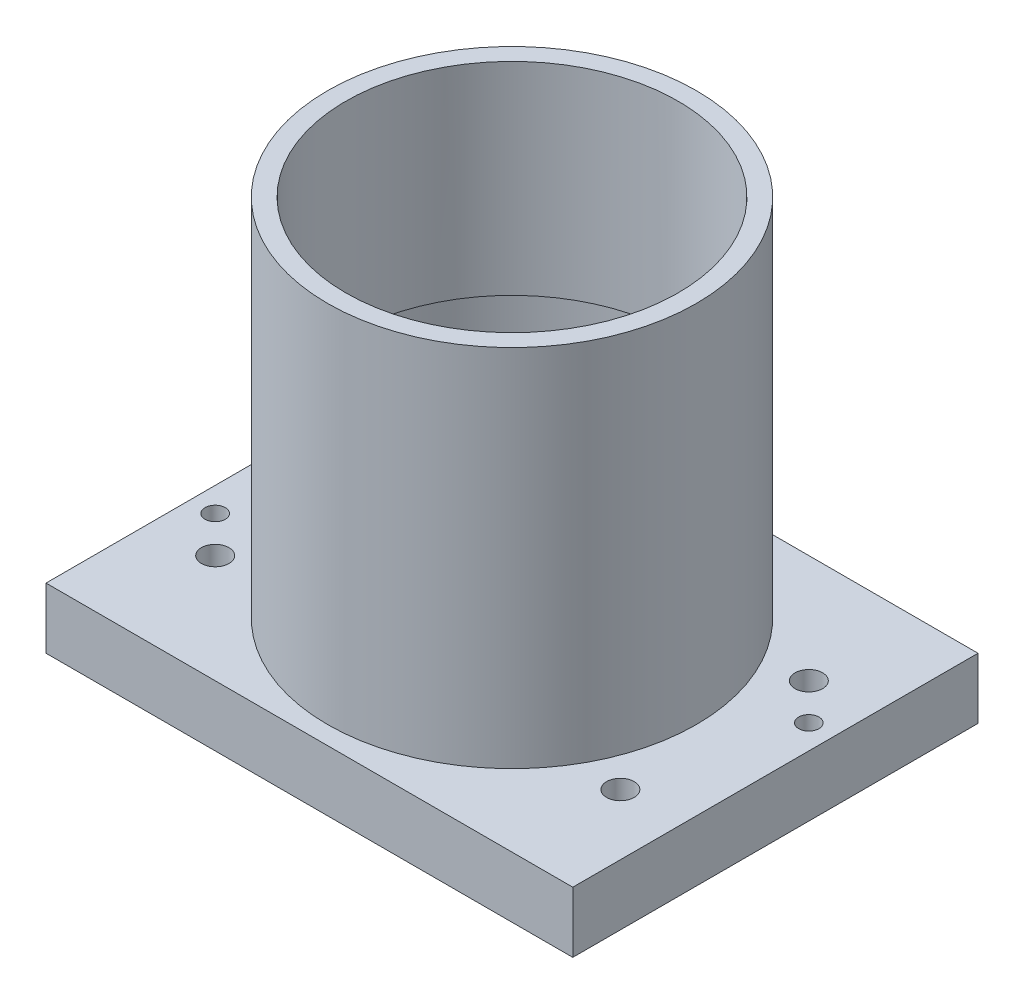
from build123d import *

# Parameters (mm, degrees)
SKETCH1_W             = 130
SKETCH1_H             = 100
BOSS_EXTRUDE1_DEPTH   = 15
SKETCH2_R             = 45.5
BOSS_EXTRUDE2_DEPTH   = 90
SKETCH3_R             = 41
CUT_EXTRUDE1_DEPTH    = 106
SKETCH4_R             = 42.5
CUT_EXTRUDE2_DEPTH    = 55
M8_TAPPED_HOLE1_D     = 6.8
M8_TAPPED_HOLE1_DEPTH = 17.707073895
M8_TAPPED_HOLE1_TIP   = 2.042926105
SKETCH11_R            = 2.5
CUT_EXTRUDE3_DEPTH    = 106


with BuildPart() as part:
    # Sketch1 → Boss-Extrude1 (new body)
    with BuildSketch(Plane(origin=(0, 0, 0), x_dir=(1, 0, 0), z_dir=(0, 1, 0))):
        Rectangle(SKETCH1_W, SKETCH1_H)
    extrude(amount=BOSS_EXTRUDE1_DEPTH)

    # Sketch2 → Boss-Extrude2 (add)
    with BuildSketch(Plane(origin=(0, 15, 0), x_dir=(1, 0, 0), z_dir=(0, 1, 0))):
        Circle(SKETCH2_R)
    extrude(amount=BOSS_EXTRUDE2_DEPTH)

    # Sketch3 → Cut-Extrude1 (cut, through all)
    with BuildSketch(Plane(origin=(0, 105, 0), x_dir=(1, 0, 0), z_dir=(0, 1, 0))):
        Circle(SKETCH3_R)
    extrude(amount=-CUT_EXTRUDE1_DEPTH, mode=Mode.SUBTRACT)

    # Sketch4 → Cut-Extrude2 (cut)
    with BuildSketch(Plane.XZ):
        Circle(SKETCH4_R)
    extrude(amount=-CUT_EXTRUDE2_DEPTH, mode=Mode.SUBTRACT)

    # M8 Tapped Hole1
    with Locations(Plane(origin=(0, 15, 0), x_dir=(1, 0, 0), z_dir=(0, 1, 0))):
        with Locations((-50, 23.25), (-50, -23.25), (50, -23.25), (50, 23.25)):
            Hole(M8_TAPPED_HOLE1_D / 2, depth=M8_TAPPED_HOLE1_DEPTH)
            with Locations((0, 0, -(M8_TAPPED_HOLE1_DEPTH + M8_TAPPED_HOLE1_TIP / 2))):  # 118° drill point
                Cone(0, M8_TAPPED_HOLE1_D / 2, M8_TAPPED_HOLE1_TIP, mode=Mode.SUBTRACT)

    # Sketch11 → Cut-Extrude3 (cut, through all)
    with BuildSketch(Plane.XZ):
        with Locations((-59, 14.25)):
            Circle(SKETCH11_R)
        with Locations((59, -14.25)):
            Circle(SKETCH11_R)
    extrude(amount=-CUT_EXTRUDE3_DEPTH, mode=Mode.SUBTRACT)


solid = part.part
